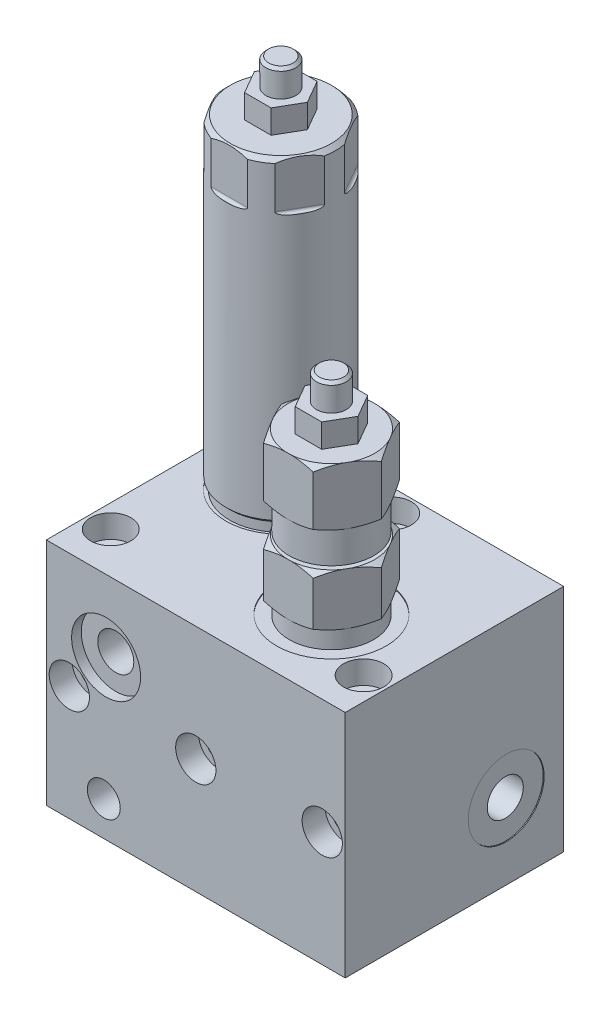
from build123d import *

# Parameters (mm, degrees)
SKETCH1_W           = 82.55
SKETCH1_H           = 60.325
SKETCH1_R           = 3.5687
BOSS_EXTRUDE1_DEPTH = 63.5
SKETCH2_R           = 5.5626
CUT_EXTRUDE1_DEPTH  = 6.35
SKETCH3_R           = 3.5687
CUT_EXTRUDE2_DEPTH  = 61.325
SKETCH4_R           = 5.5626
CUT_EXTRUDE3_DEPTH  = 6.35
SKETCH5_R           = 9.525
CUT_EXTRUDE4_DEPTH  = 2.667
SKETCH7_R           = 4.9784
CUT_EXTRUDE5_DEPTH  = 20.32
SKETCH8_R           = 4.5466
CUT_EXTRUDE6_DEPTH  = 10.668
SKETCH9_R           = 7.9375
CUT_EXTRUDE7_DEPTH  = 2.667
SKETCH10_R          = 4.5466
CUT_EXTRUDE8_DEPTH  = 12.7
SKETCH11_R          = 10.4775
CUT_EXTRUDE11_DEPTH = 0.254
SKETCH12_R          = 4.9784
CUT_EXTRUDE10_DEPTH = 17.78
SKETCH13_R          = 10.4775
CUT_EXTRUDE12_DEPTH = 0.254
SKETCH14_R          = 4.9784
CUT_EXTRUDE13_DEPTH = 13.97
SKETCH15_R          = 7.9375
SKETCH15_R_2        = 10.4775
CUT_EXTRUDE14_DEPTH = 2.667
SKETCH16_R          = 4.9784
SKETCH16_R_2        = 3.4544
CUT_EXTRUDE15_DEPTH = 15.24
SKETCH18_R          = 15.1511
CUT_EXTRUDE16_DEPTH = 0.254
SKETCH20_R          = 16.8275
CUT_EXTRUDE17_DEPTH = 40.64
BOSS_EXTRUDE3_DEPTH = 6.5532
SKETCH23_R          = 17.145
CUT_EXTRUDE18_DEPTH = 13.462
FILLET1_R           = 0.762
BOSS_EXTRUDE4_DEPTH = 6.5532


with BuildPart() as part:
    # Sketch1 → Boss-Extrude1 (new body)
    with BuildSketch(Plane(origin=(0, 0, 0), x_dir=(1, 0, 0), z_dir=(0, 1, 0))):
        Rectangle(SKETCH1_W, SKETCH1_H)
        with Locations(Location((0, 23.8125, 0), (0, 0, 270))):  # turned: the seam where the file's is
            Circle(SKETCH1_R, mode=Mode.SUBTRACT)
        with Locations(Location((-34.925, -18.7325, 0), (0, 0, 270))):  # turned: the seam where the file's is
            Circle(SKETCH1_R, mode=Mode.SUBTRACT)
        with Locations(Location((34.925, -18.7325, 0), (0, 0, 270))):  # turned: the seam where the file's is
            Circle(SKETCH1_R, mode=Mode.SUBTRACT)
    extrude(amount=BOSS_EXTRUDE1_DEPTH)

    # Sketch2 → Cut-Extrude1 (cut)
    with BuildSketch(Plane(origin=(0, 63.5, 0), x_dir=(1, 0, 0), z_dir=(0, 1, 0))):
        with Locations(Location((-34.925, -18.7325, 0), (0, 0, 270))):  # turned: the seam where the file's is
            Circle(SKETCH2_R)
        with Locations(Location((0, 23.8125, 0), (0, 0, 270))):  # turned: the seam where the file's is
            Circle(SKETCH2_R)
        with Locations(Location((34.925, -18.7325, 0), (0, 0, 270))):  # turned: the seam where the file's is
            Circle(SKETCH2_R)
    extrude(amount=-CUT_EXTRUDE1_DEPTH, mode=Mode.SUBTRACT)

    # Sketch3 → Cut-Extrude2 (cut, through all)
    with BuildSketch(Plane.XY.offset(30.1625)):
        with Locations((-34.925, 31.75)):
            Circle(SKETCH3_R)
        with Locations((0, 31.75)):
            Circle(SKETCH3_R)
        with Locations((34.925, 31.75)):
            Circle(SKETCH3_R)
    extrude(amount=-CUT_EXTRUDE2_DEPTH, mode=Mode.SUBTRACT)

    # Sketch4 → Cut-Extrude3 (cut)
    with BuildSketch(Plane.XY.offset(30.1625)):
        with Locations((-34.925, 31.75)):
            Circle(SKETCH4_R)
        with Locations((0, 31.75)):
            Circle(SKETCH4_R)
        with Locations((34.925, 31.75)):
            Circle(SKETCH4_R)
    extrude(amount=-CUT_EXTRUDE3_DEPTH, mode=Mode.SUBTRACT)

    # Sketch5 → Cut-Extrude4 (cut)
    with BuildSketch(Plane.XY.offset(30.1625)):
        with Locations((-24.765, 43.688)):
            Circle(SKETCH5_R)
    extrude(amount=-CUT_EXTRUDE4_DEPTH, mode=Mode.SUBTRACT)

    # Sketch7 → Cut-Extrude5 (cut)
    with BuildSketch(Plane.XY.offset(30.1625)):
        with Locations((-24.765, 43.688)):
            Circle(SKETCH7_R)
    extrude(amount=-CUT_EXTRUDE5_DEPTH, mode=Mode.SUBTRACT)

    # Sketch8 → Cut-Extrude6 (cut)
    with BuildSketch(Plane.XY.offset(30.1625)):
        with Locations((-25.4, 9.525)):
            Circle(SKETCH8_R)
    extrude(amount=-CUT_EXTRUDE6_DEPTH, mode=Mode.SUBTRACT)

    # Sketch9 → Cut-Extrude7 (cut)
    with BuildSketch(Plane.XZ):
        with Locations(Location((-25.4, 7.3025, 0), (0, 0, 270))):  # turned: the seam where the file's is
            Circle(SKETCH9_R)
        with Locations(Location((26.67, -10.4775, 0), (0, 0, 270))):  # turned: the seam where the file's is
            Circle(SKETCH9_R)
    extrude(amount=-CUT_EXTRUDE7_DEPTH, mode=Mode.SUBTRACT)

    # Sketch10 → Cut-Extrude8 (cut)
    with BuildSketch(Plane.XZ):
        with Locations(Location((-25.4, 7.3025, 0), (0, 0, 270))):  # turned: the seam where the file's is
            Circle(SKETCH10_R)
        with Locations(Location((26.67, -10.4775, 0), (0, 0, 270))):  # turned: the seam where the file's is
            Circle(SKETCH10_R)
    extrude(amount=-CUT_EXTRUDE8_DEPTH, mode=Mode.SUBTRACT)

    # Sketch11 → Cut-Extrude11 (cut)
    with BuildSketch(Plane(origin=(41.275, 0, 0), x_dir=(0, 0, -1), z_dir=(1, 0, 0))):
        with Locations((14.2875, 20.828)):
            Circle(SKETCH11_R)
    extrude(amount=-CUT_EXTRUDE11_DEPTH, mode=Mode.SUBTRACT)

    # Sketch12 → Cut-Extrude10 (cut)
    with BuildSketch(Plane(origin=(41.275, 0, 0), x_dir=(0, 0, -1), z_dir=(1, 0, 0))):
        with Locations((14.2875, 20.828)):
            Circle(SKETCH12_R)
    extrude(amount=-CUT_EXTRUDE10_DEPTH, mode=Mode.SUBTRACT)

    # Sketch13 → Cut-Extrude12 (cut)
    with BuildSketch(Plane.ZY.offset(41.275)):
        with Locations((7.3025, 21.336)):
            Circle(SKETCH13_R)
    extrude(amount=-CUT_EXTRUDE12_DEPTH, mode=Mode.SUBTRACT)

    # Sketch14 → Cut-Extrude13 (cut)
    with BuildSketch(Plane.ZY.offset(41.275)):
        with Locations((7.3025, 21.336)):
            Circle(SKETCH14_R)
    extrude(amount=-CUT_EXTRUDE13_DEPTH, mode=Mode.SUBTRACT)

    # Sketch15 → Cut-Extrude14 (cut)
    with BuildSketch(Plane(origin=(0, 0, -30.1625), x_dir=(-1, 0, 0), z_dir=(0, 0, -1))):
        with Locations((-25.4, 9.525)):
            Circle(SKETCH15_R)
        with Locations((25.4, 9.525)):
            Circle(SKETCH15_R)
        with Locations((-15.875, 51.3588)):
            Circle(SKETCH15_R_2)
    extrude(amount=-CUT_EXTRUDE14_DEPTH, mode=Mode.SUBTRACT)

    # Sketch16 → Cut-Extrude15 (cut)
    with BuildSketch(Plane(origin=(0, 0, -30.1625), x_dir=(-1, 0, 0), z_dir=(0, 0, -1))):
        with Locations((-15.875, 51.3588)):
            Circle(SKETCH16_R)
        with Locations((-25.4, 9.525)):
            Circle(SKETCH16_R_2)
        with Locations((25.4, 9.525)):
            Circle(SKETCH16_R_2)
    extrude(amount=-CUT_EXTRUDE15_DEPTH, mode=Mode.SUBTRACT)

    # Sketch18 → Cut-Extrude16 (cut)
    with BuildSketch(Plane(origin=(0, 63.5, 0), x_dir=(1, 0, 0), z_dir=(0, 1, 0))):
        with Locations(Location((15.875, -8.5725, 0), (0, 0, 270))):  # turned: the seam where the file's is
            Circle(SKETCH18_R)
        with Locations(Location((-20.955, 14.2875, 0), (0, 0, 270))):  # turned: the seam where the file's is
            Circle(SKETCH18_R)
    extrude(amount=-CUT_EXTRUDE16_DEPTH, mode=Mode.SUBTRACT)

    # Sketch19 → Revolve1 (revolve)
    with BuildSketch(Plane.XY.offset(8.5725), mode=Mode.PRIVATE) as revolve1_sk:
        Polygon((15.875, 63.246), (27.5336, 63.246), (27.5336, 68.072), (29.6545, 69.296502186), (29.6545, 81.486809479), (27.813, 82.55), (24.384, 82.55), (24.384, 83.312), (27.5336, 83.312), (27.5336, 91.948), (29.6545, 93.172502186), (29.6545, 106.886809479), (27.813, 107.95), (20.0025, 107.95), (20.0025, 121.158), (19.2405, 121.92), (15.875, 121.92), align=None)
    revolve(revolve1_sk.sketch.rotate(Axis((15.875, 49.904361665, 8.5725), (0, 1, 0)), 90), axis=Axis((15.875, 49.904361665, 8.5725), (0, 1, 0)))  # turned: the seam where the file's is

    # Sketch20 → Cut-Extrude17 (cut)
    with BuildSketch(Plane(origin=(0, 107.95, 0), x_dir=(1, 0, 0), z_dir=(0, 1, 0))):
        with Locations((15.875, -8.5725)):
            Circle(SKETCH20_R)
        Polygon((22.752742817, 3.3401), (8.997257183, 3.3401), (2.119514367, -8.5725), (8.997257183, -20.4851), (22.752742817, -20.4851), (29.630485633, -8.5725), align=None, mode=Mode.SUBTRACT)
    extrude(amount=-CUT_EXTRUDE17_DEPTH, mode=Mode.SUBTRACT)

    # Sketch21 → Boss-Extrude3 (add)
    with BuildSketch(Plane(origin=(0, 107.95, 0), x_dir=(1, 0, 0), z_dir=(0, 1, 0))):
        Polygon((19.541174209, -2.2225), (12.208825791, -2.2225), (8.542651581, -8.5725), (12.208825791, -14.9225), (19.541174209, -14.9225), (23.207348419, -8.5725), align=None)
    extrude(amount=BOSS_EXTRUDE3_DEPTH)

    # Sketch22 → Revolve2 (revolve)
    with BuildSketch(Plane.XY.offset(-14.2875), mode=Mode.PRIVATE) as revolve2_sk:
        Polygon((-20.955, 63.246), (-6.7945, 63.246), (-6.7945, 65.786), (-5.8674, 66.7131), (-5.8674, 152.0698), (-7.0104, 153.2128), (-16.8275, 153.2128), (-16.8275, 166.4208), (-17.5895, 167.1828), (-20.955, 167.1828), align=None)
    revolve(revolve2_sk.sketch.rotate(Axis((-20.955, 155.604867865, -14.2875), (0, -1, 0)), 180), axis=Axis((-20.955, 155.604867865, -14.2875), (0, -1, 0)))  # turned: the seam where the file's is

    # Sketch23 → Cut-Extrude18 (cut)
    with BuildSketch(Plane(origin=(0, 153.2128, 0), x_dir=(1, 0, 0), z_dir=(0, 1, 0))):
        with Locations((-20.955, 14.2875)):
            Circle(SKETCH23_R)
        Polygon((-29.167230229, 0.0635), (-12.742769771, 0.0635), (-4.530539542, 14.2875), (-12.742769771, 28.5115), (-29.167230229, 28.5115), (-37.379460458, 14.2875), align=None, mode=Mode.SUBTRACT)
    extrude(amount=-CUT_EXTRUDE18_DEPTH, mode=Mode.SUBTRACT)

    # Fillet1
    fillet1_edges = [part.edges().sort_by_distance(p)[0] for p in [
        (-33.273345343, 139.7508, -7.1755),
        (-20.955, 139.7508, -0.0635),
        (-8.636654657, 139.7508, -7.1755),
        (-8.636654657, 139.7508, -21.3995),
        (-20.955, 139.7508, -28.5115),
        (-33.273345343, 139.7508, -21.3995),
    ]]
    fillet(fillet1_edges, radius=FILLET1_R)

    # Sketch24 → Boss-Extrude4 (add)
    with BuildSketch(Plane(origin=(0, 153.2128, 0), x_dir=(1, 0, 0), z_dir=(0, 1, 0))):
        Polygon((-24.621174209, 7.9375), (-17.288825791, 7.9375), (-13.622651581, 14.2875), (-17.288825791, 20.6375), (-24.621174209, 20.6375), (-28.287348419, 14.2875), align=None)
    extrude(amount=BOSS_EXTRUDE4_DEPTH)


solid = part.part
